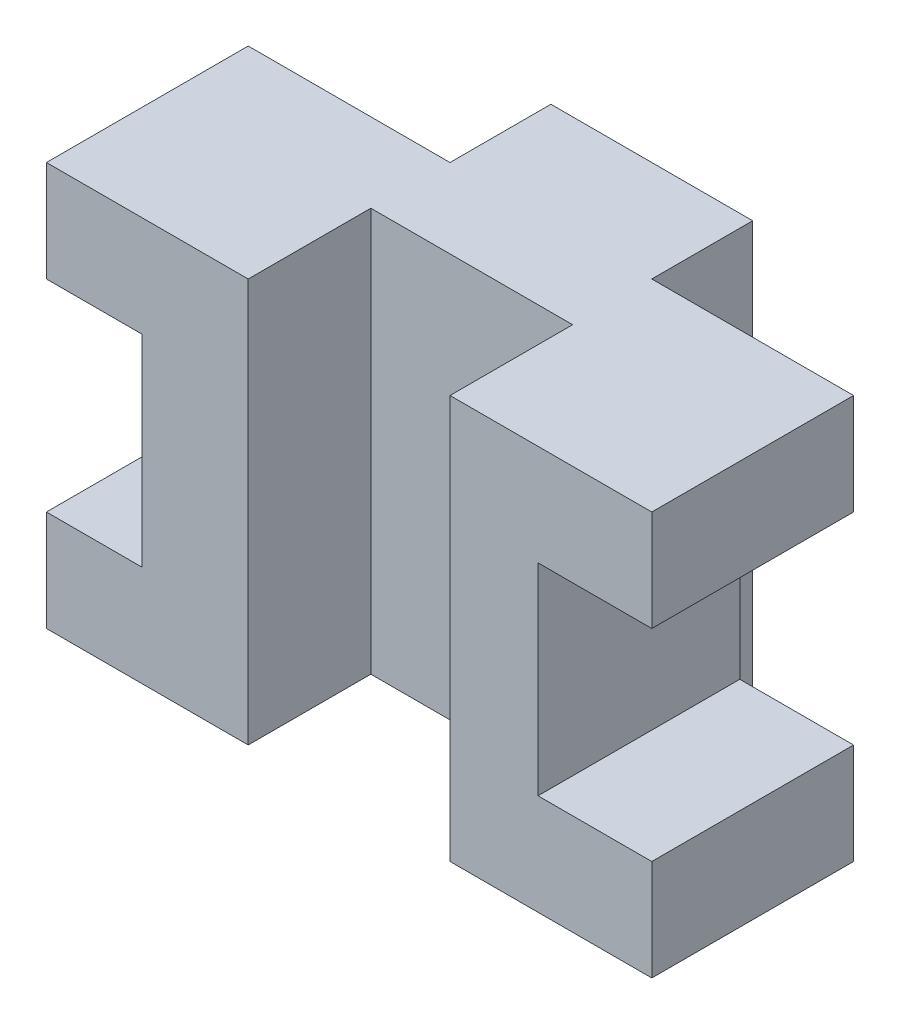
from build123d import *

# Parameters (mm, degrees)
CROQUIS1_W              = 60
CROQUIS1_H              = 30
SALIENTE_EXTRUIR2_DEPTH = 40
CROQUIS2_W              = 20
CROQUIS2_H              = 12.153687435
CORTAR_EXTRUIR1_DEPTH   = 41
CROQUIS3_W              = 20
CROQUIS3_H              = 10
CORTAR_EXTRUIR2_DEPTH   = 41
CROQUIS4_W              = 20
CROQUIS4_H              = 10
CORTAR_EXTRUIR3_DEPTH   = 41
CROQUIS5_W              = 11.276599724
CROQUIS5_H              = 20
CORTAR_EXTRUIR4_DEPTH   = 40
CROQUIS6_W              = 9.488499603
CROQUIS6_H              = 20
CORTAR_EXTRUIR5_DEPTH   = 40


with BuildPart() as part:
    # Croquis1 → Saliente-Extruir2 (new body)
    with BuildSketch(Plane(origin=(0, 0, 0), x_dir=(1, 0, 0), z_dir=(0, 1, 0))):
        Rectangle(CROQUIS1_W, CROQUIS1_H)
    extrude(amount=SALIENTE_EXTRUIR2_DEPTH)

    # Croquis2 → Cortar-Extruir1 (cut, through all)
    with BuildSketch(Plane(origin=(0, 40, 0), x_dir=(1, 0, 0), z_dir=(0, 1, 0))):
        with Locations((0, -8.923156283)):
            Rectangle(CROQUIS2_W, CROQUIS2_H)
    extrude(amount=-CORTAR_EXTRUIR1_DEPTH, mode=Mode.SUBTRACT)

    # Croquis3 → Cortar-Extruir2 (cut, through all)
    with BuildSketch(Plane(origin=(0, 40, 0), x_dir=(1, 0, 0), z_dir=(0, 1, 0))):
        with Locations((-20, 10)):
            Rectangle(CROQUIS3_W, CROQUIS3_H)
    extrude(amount=-CORTAR_EXTRUIR2_DEPTH, mode=Mode.SUBTRACT)

    # Croquis4 → Cortar-Extruir3 (cut, through all)
    with BuildSketch(Plane(origin=(0, 40, 0), x_dir=(1, 0, 0), z_dir=(0, 1, 0))):
        with Locations((20, 10)):
            Rectangle(CROQUIS4_W, CROQUIS4_H)
    extrude(amount=-CORTAR_EXTRUIR3_DEPTH, mode=Mode.SUBTRACT)

    # Croquis5 → Cortar-Extruir4 (cut)
    with BuildSketch(Plane.XY.offset(15)):
        with Locations((24.361700138, 20)):
            Rectangle(CROQUIS5_W, CROQUIS5_H)
    extrude(amount=-CORTAR_EXTRUIR4_DEPTH, mode=Mode.SUBTRACT)

    # Croquis6 → Cortar-Extruir5 (cut)
    with BuildSketch(Plane.XY.offset(15)):
        with Locations((-25.255750199, 20)):
            Rectangle(CROQUIS6_W, CROQUIS6_H)
    extrude(amount=-CORTAR_EXTRUIR5_DEPTH, mode=Mode.SUBTRACT)


solid = part.part
